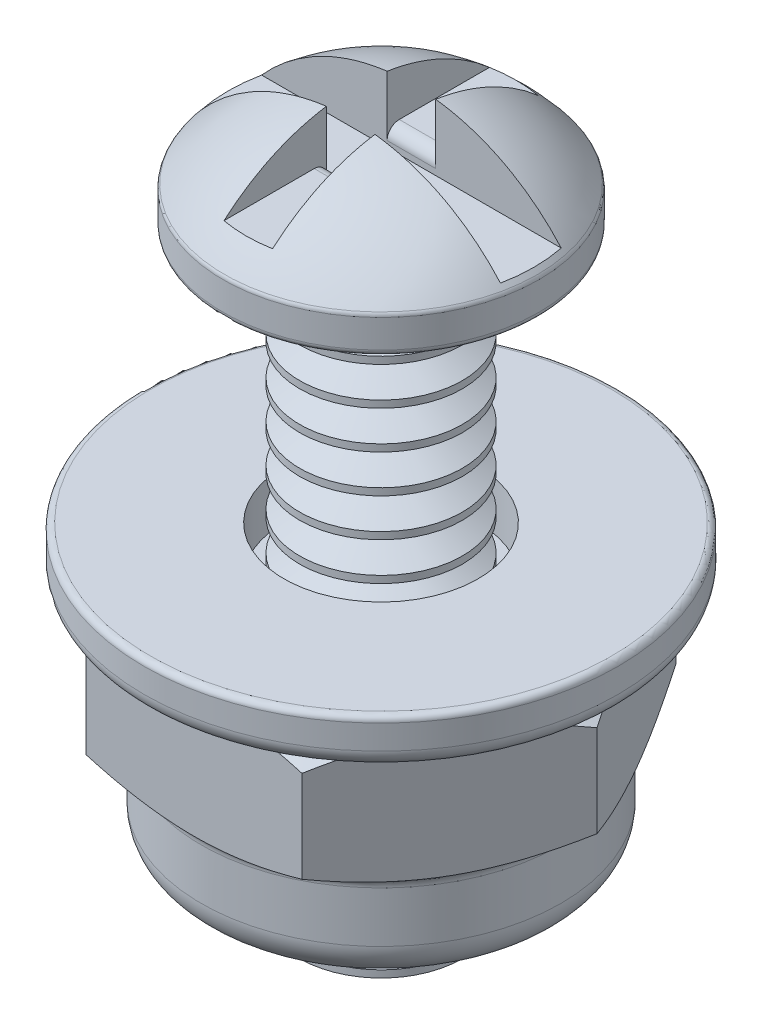
from build123d import *

# Parameters (mm, degrees)
SKETCH2_W                          = 1.27
SKETCH2_H                          = 1.778
LONG_CUT_PHILLIPS_DEPTH            = 14.53131218
LONG_CUT_PHILLIPS_DEPTH_BACK       = 14.53131218
SKETCH3_W                          = 1.016
SKETCH3_H                          = 1.27
SHORT_CUT_PHILLIPS_DEPTH           = 14.53131218
SHORT_CUT_PHILLIPS_DEPTH_BACK      = 14.53131218
PHILLIPS_FILLET_R                  = 0.254
LPATTERN_THREADS_COUNT             = 16
LPATTERN_THREADS_PITCH             = 0.79375
SKETCH5_R                          = 1.35255
NUT_TAP_HOLE_36_DRILL_0_1065_DEPTH = 2.794
SKETCH8_R                          = 3.7592
SKETCH8_R_2                        = 1.35255
LOCK_NUT_EXTRUDE_DEPTH             = 1.9685
SKETCH9_R                          = 1.778
LOCK_NUT_CUT_DEPTH                 = 0.508
LOCK_NUT_FILLET_1_R                = 0.762
LOCK_NUT_FILLET_2_R                = 0.254
SKETCH7_R                          = 4.953
SKETCH7_R_2                        = 2.032
WASHER_DEPTH                       = 1.016
WASHER_FILLET_1_R                  = 0.381
WASHER_FILLET_2_R                  = 0.127


with BuildPart() as part:
    # Sketch1 → Revolve Screw Body (revolve)
    with BuildSketch(Plane.XY, mode=Mode.PRIVATE) as revolve_screw_body_sk:
        with BuildLine():
            Line((0, 2.3495), (0, -12.7))
            Line((0, -12.7), (1.7018, -12.7))
            Line((1.7018, -12.7), (1.7018, 0))
            Line((1.7018, 0), (3.175, 0))
            ThreePointArc((3.175, 0), (3.264802561, 0.037197439), (3.302, 0.127))
            Line((3.302, 0.127), (3.302, 0.717085514))
            ThreePointArc((3.302, 0.717085514), (3.294617332, 0.759755103), (3.273327656, 0.79746382))
            ThreePointArc((3.273327656, 0.79746382), (1.811317907, 1.941836743), (0, 2.3495))
        make_face()
    revolve(revolve_screw_body_sk.sketch.rotate(Axis((0, 2.3495, 0), (0, -1, 0)), 180), axis=Axis((0, 2.3495, 0), (0, -1, 0)))

    # Sketch2 → Long Cut Phillips (cut, two sides)
    with BuildSketch(Plane(origin=(0, 0, 0), x_dir=(0, 0, -1), z_dir=(1, 0, 0))) as long_cut_phillips_sk:
        with Locations((0, 1.778)):
            Rectangle(SKETCH2_W, SKETCH2_H)
    extrude(amount=LONG_CUT_PHILLIPS_DEPTH, mode=Mode.SUBTRACT)
    extrude(long_cut_phillips_sk.sketch, amount=-LONG_CUT_PHILLIPS_DEPTH_BACK, mode=Mode.SUBTRACT)

    # Sketch3 → Short Cut Phillips (cut, two sides)
    with BuildSketch(Plane.XY) as short_cut_phillips_sk:
        with Locations((0, 1.905)):
            Rectangle(SKETCH3_W, SKETCH3_H)
    extrude(amount=SHORT_CUT_PHILLIPS_DEPTH, mode=Mode.SUBTRACT)
    extrude(short_cut_phillips_sk.sketch, amount=-SHORT_CUT_PHILLIPS_DEPTH_BACK, mode=Mode.SUBTRACT)

    # Phillips Fillet
    phillips_fillet_edges = [part.edges().sort_by_distance(p)[0] for p in [
        (0, 1.27, -0.635),
        (0, 1.27, 0.635),
    ]]
    fillet(phillips_fillet_edges, radius=PHILLIPS_FILLET_R)

    # Sketch4 → Cut Threading (revolve, cut)
    with BuildSketch(Plane.XY, mode=Mode.PRIVATE) as cut_threading_sk:
        Polygon((2.624157664, -12.303125), (2.624157664, -13.096875), (1.830407664, -13.096875), (1.143, -12.7), (1.830407664, -12.303125), align=None)
    cut_threading = revolve(cut_threading_sk.sketch.rotate(Axis((0, -12.7, 0), (0, 1, 0)), 270), axis=Axis((0, -12.7, 0), (0, 1, 0)), mode=Mode.SUBTRACT)

    # LPattern Threads: Cut Threading ×16
    with Locations(*[(0, i * LPATTERN_THREADS_PITCH, 0) for i in range(1, LPATTERN_THREADS_COUNT)]):
        add(cut_threading, mode=Mode.SUBTRACT)


with BuildPart() as body_2:
    # Sketch5 → Nut Tap Hole #36 Drill 0.1065 (new body)
    with BuildSketch(Plane(origin=(0, -6.35, 0), x_dir=(-1, 0, 0), z_dir=(0, -1, 0))):
        Polygon((-4.516726626, 0), (-2.258363313, -3.9116), (2.258363313, -3.9116), (4.516726626, 0), (2.258363313, 3.9116), (-2.258363313, 3.9116), align=None)
        with Locations(Location((0, 0, 0), (0, 0, 180))):
            Circle(SKETCH5_R, mode=Mode.SUBTRACT)
    extrude(amount=NUT_TAP_HOLE_36_DRILL_0_1065_DEPTH)

    # Sketch6 → Nut Angle Edges (revolve, cut)
    with BuildSketch(Plane.XY, mode=Mode.PRIVATE) as nut_angle_edges_sk:
        Polygon((3.7592, -6.35), (4.516726626, -6.35), (4.516726626, -6.787358201), align=None)
        Polygon((3.7592, -9.144), (4.516726626, -9.144), (4.516726626, -8.706641799), align=None)
    revolve(nut_angle_edges_sk.sketch.rotate(Axis((0, -6.35, 0), (0, -1, 0)), 270), axis=Axis((0, -6.35, 0), (0, -1, 0)), mode=Mode.SUBTRACT)

    # Sketch8 → Lock Nut Extrude (add)
    with BuildSketch(Plane.XZ.offset(9.144)):
        with Locations(Location((0, 0, 0), (0, 0, 270))):
            Circle(SKETCH8_R)
        with Locations(Location((0, 0, 0), (0, 0, 270))):
            Circle(SKETCH8_R_2, mode=Mode.SUBTRACT)
    extrude(amount=LOCK_NUT_EXTRUDE_DEPTH)

    # Sketch9 → Lock Nut Cut (cut)
    with BuildSketch(Plane.XZ.offset(11.1125)):
        with Locations(Location((0, 0, 0), (0, 0, 270))):
            Circle(SKETCH9_R)
    extrude(amount=-LOCK_NUT_CUT_DEPTH, mode=Mode.SUBTRACT)

    # Lock Nut Fillet-1
    lock_nut_fillet_1_edges = [body_2.edges().sort_by_distance(p)[0] for p in [
        (0, -11.1125, 3.7592),
    ]]
    fillet(lock_nut_fillet_1_edges, radius=LOCK_NUT_FILLET_1_R)

    # Lock Nut Fillet-2
    lock_nut_fillet_2_edges = [body_2.edges().sort_by_distance(p)[0] for p in [
        (0, -9.144, 3.7592),
        (0, -11.1125, 1.778),
    ]]
    fillet(lock_nut_fillet_2_edges, radius=LOCK_NUT_FILLET_2_R)


with BuildPart() as body_3:
    # Sketch7 → Washer (new body)
    with BuildSketch(Plane.XZ.offset(6.35)):
        with Locations(Location((0, 0, 0), (0, 0, 270))):
            Circle(SKETCH7_R)
        with Locations(Location((0, 0, 0), (0, 0, 270))):
            Circle(SKETCH7_R_2, mode=Mode.SUBTRACT)
    extrude(amount=-WASHER_DEPTH)

    # Washer Fillet-1
    washer_fillet_1_edges = [body_3.edges().sort_by_distance(p)[0] for p in [
        (0, -6.35, 4.953),
    ]]
    fillet(washer_fillet_1_edges, radius=WASHER_FILLET_1_R)

    # Washer Fillet-2
    washer_fillet_2_edges = [body_3.edges().sort_by_distance(p)[0] for p in [
        (0, -5.334, 4.953),
    ]]
    fillet(washer_fillet_2_edges, radius=WASHER_FILLET_2_R)


solid = Compound([part.part, body_2.part, body_3.part])
